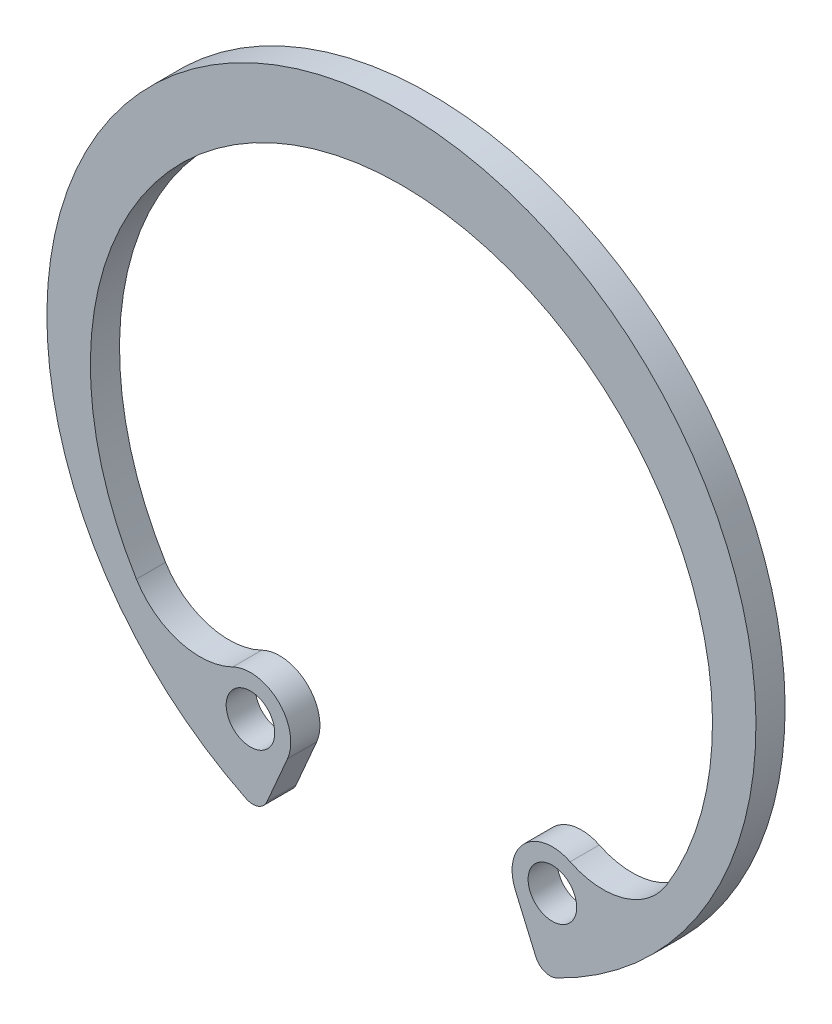
from build123d import *

# Parameters (mm, degrees)
SKETCH3_R                = 1.25
BOSS_EXTRUDE1_DEPTH      = 0.75
BOSS_EXTRUDE1_DEPTH_BACK = 0.75
FILLET1_R                = 0.79375


with BuildPart() as part:
    # Sketch3 → Boss-Extrude1 (new body, two sides)
    with BuildSketch(Plane.XY) as boss_extrude1_sk:
        with BuildLine():
            Line((-5.8660137, -13.566130003), (-7.243190661, -16.751080235))
            ThreePointArc((-7.243190661, -16.751080235), (0, 18.25), (7.243190661, -16.751080235))
            Line((7.243190661, -16.751080235), (5.8660137, -13.566130003))
            ThreePointArc((5.8660137, -13.566130003), (6.338884196, -11.240641223), (8.684339918, -10.879612098))
            ThreePointArc((8.684339918, -10.879612098), (11.441621609, -11.12015326), (13.643394773, -9.443055377))
            ThreePointArc((13.643394773, -9.443055377), (0, 14.95), (-13.643394773, -9.443055377))
            ThreePointArc((-13.643394773, -9.443055377), (-11.441621609, -11.12015326), (-8.684339918, -10.879612098))
            ThreePointArc((-8.684339918, -10.879612098), (-6.338884196, -11.240641223), (-5.8660137, -13.566130003))
        make_face()
        with Locations((-7.770588576, -12.742589147)):
            Circle(SKETCH3_R, mode=Mode.SUBTRACT)
        with Locations((7.770588576, -12.742589147)):
            Circle(SKETCH3_R, mode=Mode.SUBTRACT)
    extrude(amount=BOSS_EXTRUDE1_DEPTH)
    extrude(boss_extrude1_sk.sketch, amount=-BOSS_EXTRUDE1_DEPTH_BACK)

    # Fillet1
    fillet1_edges = [part.edges().sort_by_distance(p)[0] for p in [
        (7.243190661, -16.751080235, 0),
        (-7.243190661, -16.751080235, 0),
    ]]
    fillet(fillet1_edges, radius=FILLET1_R)


solid = part.part
